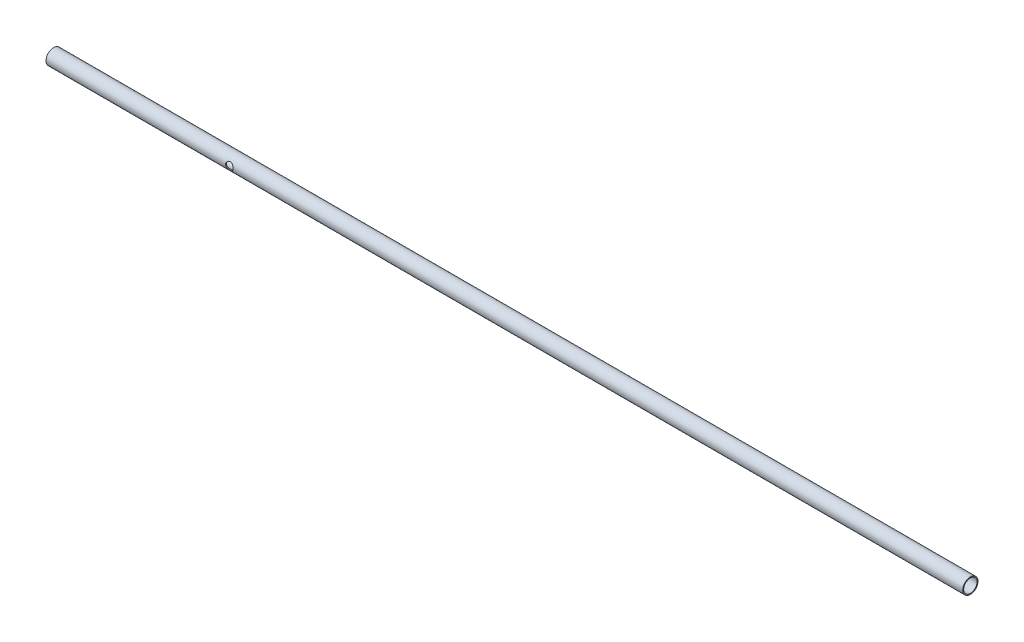
from build123d import *

# Parameters (mm, degrees)
SKETCH2_R               = 6.35
SKETCH2_R_2             = 5.55625
SKETCH3_R               = 3.175
CUT_EXTRUDE1_DEPTH      = 7.35
CUT_EXTRUDE1_DEPTH_BACK = 7.35


with BuildPart() as part:
    # Sweep1: sweep along a path in Sketch1
    with BuildLine(Plane.XY) as sweep1_path:
        Line((0, 0), (762, 0))
    # Sketch2 → Sweep1 (sweep)
    with BuildSketch(Plane(origin=(0, 0, 0), x_dir=(0, 0, -1), z_dir=(1, 0, 0))):
        Circle(SKETCH2_R)
        Circle(SKETCH2_R_2, mode=Mode.SUBTRACT)
    sweep(path=sweep1_path.line)

    # Sketch3 → Cut-Extrude1 (cut, two sides)
    with BuildSketch(Plane.XY) as cut_extrude1_sk:
        with Locations((152.4, 0)):
            Circle(SKETCH3_R)
    extrude(amount=CUT_EXTRUDE1_DEPTH, mode=Mode.SUBTRACT)
    extrude(cut_extrude1_sk.sketch, amount=-CUT_EXTRUDE1_DEPTH_BACK, mode=Mode.SUBTRACT)


solid = part.part
